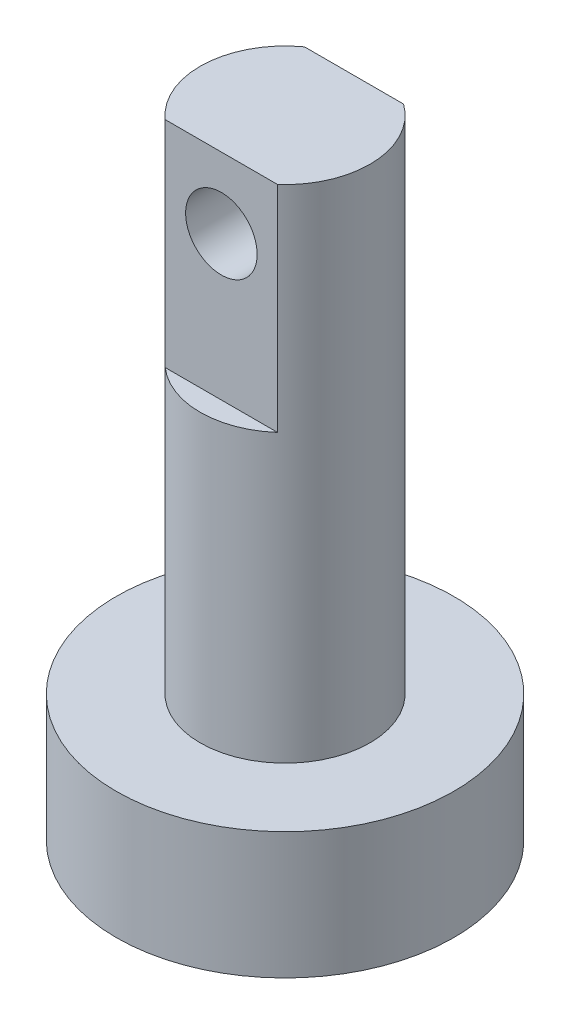
from build123d import *

# Parameters (mm, degrees)
SKETCH1_R           = 59.910502434
BOSS_EXTRUDE1_DEPTH = 44.958
SKETCH2_R           = 30.133554255
BOSS_EXTRUDE2_DEPTH = 177.8
SKETCH3_W           = 54.540648196
SKETCH3_H           = 11.308105597
SKETCH3_H_2         = 15.077164852
CUT_EXTRUDE4_DEPTH  = 76.2
SKETCH5_R           = 12.7
CUT_EXTRUDE5_DEPTH  = 246.625869205


with BuildPart() as part:
    # Sketch1 → Boss-Extrude1 (new body)
    with BuildSketch(Plane(origin=(0, 0, 0), x_dir=(1, 0, 0), z_dir=(0, 1, 0))):
        Circle(SKETCH1_R)
    extrude(amount=BOSS_EXTRUDE1_DEPTH)

    # Sketch2 → Boss-Extrude2 (add)
    with BuildSketch(Plane(origin=(0, 44.958, 0), x_dir=(1, 0, 0), z_dir=(0, 1, 0))):
        Circle(SKETCH2_R)
    extrude(amount=BOSS_EXTRUDE2_DEPTH)

    # Sketch3 → Cut-Extrude4 (cut)
    with BuildSketch(Plane(origin=(0, 222.758, 0), x_dir=(1, 0, 0), z_dir=(0, 1, 0))):
        with Locations((0, 30.133554255)):
            Rectangle(SKETCH3_W, SKETCH3_H)
        with Locations((0, -30.133554255)):
            Rectangle(SKETCH3_W, SKETCH3_H_2)
    extrude(amount=-CUT_EXTRUDE4_DEPTH, mode=Mode.SUBTRACT)

    # Sketch5 → Cut-Extrude5 (cut, through all)
    with BuildSketch(Plane(origin=(0, 0, -24.479501456), x_dir=(-1, 0, 0), z_dir=(0, 0, -1))):
        with Locations((0, 197.652270739)):
            Circle(SKETCH5_R)
    extrude(amount=-CUT_EXTRUDE5_DEPTH, mode=Mode.SUBTRACT)


solid = part.part
